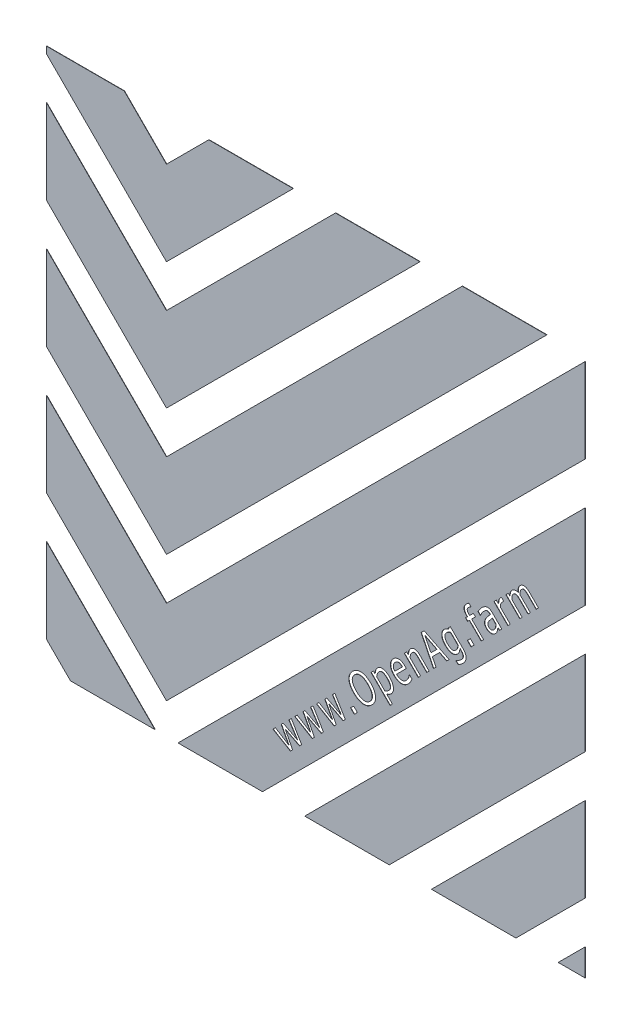
from build123d import *

# Parameters (mm, degrees)
SKETCH1_W           = 228.981
SKETCH1_H           = 228.6
BOSS_EXTRUDE1_DEPTH = 0.127
CUT_EXTRUDE1_DEPTH  = 1.127
CUT_EXTRUDE2_DEPTH  = 1.127


with BuildPart() as part:
    # Sketch1 → Boss-Extrude1 (new body)
    with BuildSketch(Plane.XY):
        Rectangle(SKETCH1_W, SKETCH1_H)
    extrude(amount=BOSS_EXTRUDE1_DEPTH)

    # Sketch2 → Cut-Extrude1 (cut, through all)
    with BuildSketch(Plane.XY.offset(0.127)):
        Polygon((-63.5, 114.3), (834.525612107, 1012.325612107), (834.525612107, 994.365099865), (-63.5, 96.339487758), (-961.525612107, 994.365099865), (-961.525612107, 1012.325612107), align=None)
        Polygon((834.525612107, 958.444075381), (834.525612107, 940.483563138), (-63.5, 42.457951031), (-961.525612107, 940.483563138), (-961.525612107, 958.444075381), (-63.5, 60.418463274), align=None)
        Polygon((834.525612107, 904.562538654), (834.525612107, 886.602026412), (-63.5, -11.423585695), (-961.525612107, 886.602026412), (-961.525612107, 904.562538654), (-63.5, 6.536926547), align=None)
        Polygon((834.525612107, 850.681001928), (834.525612107, 832.720489686), (-63.5, -65.305122421), (-961.525612107, 832.720489686), (-961.525612107, 850.681001928), (-63.5, -47.344610179), align=None)
        Polygon((834.525612107, 796.799465201), (834.525612107, 778.838952959), (-63.5, -119.186659148), (-961.525612107, 778.838952959), (-961.525612107, 796.799465201), (-63.5, -101.226146906), align=None)
        Polygon((834.525612107, 742.917928475), (834.525612107, 724.957416233), (-63.5, -173.068195874), (-961.525612107, 724.957416233), (-961.525612107, 742.917928475), (-63.5, -155.107683632), align=None)
        Polygon((834.525612107, 689.036391748), (834.525612107, 671.075879506), (-63.5, -226.949732601), (-961.525612107, 671.075879506), (-961.525612107, 689.036391748), (-63.5, -208.989220358), align=None)
        Polygon((834.525612107, 635.154855022), (834.525612107, 617.19434278), (-63.5, -280.831269327), (-961.525612107, 617.19434278), (-961.525612107, 635.154855022), (-63.5, -262.870757085), align=None)
        Polygon((834.525612107, 581.273318296), (834.525612107, 563.312806053), (-63.5, -334.712806053), (-961.525612107, 563.312806053), (-961.525612107, 581.273318296), (-63.5, -316.752293811), align=None)
        Polygon((834.525612107, 527.391781569), (834.525612107, 509.431269327), (-63.5, -388.59434278), (-961.525612107, 509.431269327), (-961.525612107, 527.391781569), (-63.5, -370.633830538), align=None)
        Polygon((834.525612107, 473.510244843), (834.525612107, 455.549732601), (-63.5, -442.475879506), (-961.525612107, 455.549732601), (-961.525612107, 473.510244843), (-63.5, -424.515367264), align=None)
        Polygon((834.525612107, 419.628708116), (834.525612107, 401.668195874), (-63.5, -496.357416233), (-961.525612107, 401.668195874), (-961.525612107, 419.628708116), (-63.5, -478.396903991), align=None)
        Polygon((834.525612107, 365.74717139), (834.525612107, 347.786659148), (-63.5, -550.238952959), (-961.525612107, 347.786659148), (-961.525612107, 365.74717139), (-63.5, -532.278440717), align=None)
        Polygon((834.525612107, 311.865634664), (834.525612107, 293.905122421), (-63.5, -604.120489686), (-961.525612107, 293.905122421), (-961.525612107, 311.865634664), (-63.5, -586.159977443), align=None)
        Polygon((834.525612107, 257.984097937), (834.525612107, 240.023585695), (-63.5, -658.002026412), (-961.525612107, 240.023585695), (-961.525612107, 257.984097937), (-63.5, -640.04151417), align=None)
        Polygon((834.525612107, 204.102561211), (834.525612107, 186.142048969), (-63.5, -711.883563138), (-961.525612107, 186.142048969), (-961.525612107, 204.102561211), (-63.5, -693.923050896), align=None)
        Polygon((834.525612107, 150.221024484), (834.525612107, 132.260512242), (-63.5, -765.765099865), (-961.525612107, 132.260512242), (-961.525612107, 150.221024484), (-63.5, -747.804587623), align=None)
        Polygon((834.525612107, 96.339487758), (834.525612107, 78.378975516), (-63.5, -819.646636591), (-961.525612107, 78.378975516), (-961.525612107, 96.339487758), (-63.5, -801.686124349), align=None)
        Polygon((834.525612107, 42.457951031), (834.525612107, 24.497438789), (-63.5, -873.528173318), (-961.525612107, 24.497438789), (-961.525612107, 42.457951031), (-63.5, -855.567661075), align=None)
        Polygon((834.525612107, -11.423585695), (834.525612107, -29.384097937), (-63.5, -927.409710044), (-961.525612107, -29.384097937), (-961.525612107, -11.423585695), (-63.5, -909.449197802), align=None)
    extrude(amount=-CUT_EXTRUDE1_DEPTH, mode=Mode.SUBTRACT)

    # Sketch3 → Cut-Extrude2 (cut, through all)
    with BuildSketch(Plane.XY.offset(0.127)):
        Polygon((-10.447003351, -81.210380229), (-6.029633889, -88.6570614), (-6.961034205, -89.588461716), (-12.994790139, -86.475504833), (-9.870529854, -92.497957365), (-10.79740881, -93.424836321), (-18.259914743, -89.023291621), (-17.213219727, -87.976596605), (-11.561518778, -91.512300719), (-14.737774711, -85.50115159), (-13.910365692, -84.673742571), (-7.860784996, -87.811566938), (-11.491437686, -82.254814564), align=None)
        Polygon((-1.178502119, -71.941878997), (3.238867343, -79.388560168), (2.307467027, -80.319960484), (-3.726288907, -77.207003602), (-0.602028622, -83.229456133), (-1.528907578, -84.156335089), (-8.991413511, -79.75479039), (-7.944718496, -78.708095374), (-2.293017546, -82.243799488), (-5.46927348, -76.232650358), (-4.641864461, -75.405241339), (1.407716235, -78.543065706), (-2.222936454, -72.986313333), align=None)
        Polygon((8.089999113, -62.673377765), (12.507368575, -70.120058936), (11.575968258, -71.051459253), (5.542212325, -67.93850237), (8.666472609, -73.960954902), (7.739593654, -74.887833857), (0.27708772, -70.486289158), (1.323782736, -69.439594142), (6.975483685, -72.975298256), (3.799227752, -66.964149126), (4.626636771, -66.136740107), (10.676217467, -69.274564474), (7.045564777, -63.717812101), align=None)
        Polygon((17.647867433, -64.979560078), (16.345715534, -66.281711977), (14.754196547, -64.69019299), (16.056348446, -63.388041091), align=None)
        with BuildLine():
            add(Edge.make_bspline(
                [(19.304709374, -49.265807535), (19.471059167, -49.280830519), (19.808375555, -49.311293428), (20.313197827, -49.429785868), (20.823195349, -49.599020368), (21.335448339, -49.829332674), (21.846274935, -50.118732028), (22.357241063, -50.461907248), (22.85714262, -50.872605401), (23.176216369, -51.177699523), (23.340023852, -51.334330083)],
                knots=[0, 0, 0, 0, 0.000500551, 0.001014993, 0.001551161, 0.002110774, 0.002696831, 0.003310675, 0.003955033, 0.004634836, 0.004634836, 0.004634836, 0.004634836], degree=3))
            add(Edge.make_bspline(
                [(23.340023852, -51.334330083), (23.493986675, -51.494092257), (23.794513245, -51.805938829), (24.194261422, -52.30213131), (24.538829272, -52.806475395), (24.829342538, -53.317299037), (25.063089531, -53.83016175), (25.239425424, -54.341315835), (25.356725509, -54.850892024), (25.385354159, -55.192007697), (25.399503678, -55.360601839)],
                knots=[0, 0, 0, 0, 0.00066537, 0.001298764, 0.001908867, 0.002496035, 0.003059566, 0.003597181, 0.004116035, 0.004623078, 0.004623078, 0.004623078, 0.004623078], degree=3))
            add(Edge.make_bspline(
                [(25.399503678, -55.360601839), (25.402770364, -55.53330125), (25.409239663, -55.875312778), (25.348404407, -56.382520672), (25.23042187, -56.874063043), (25.054216063, -57.348650398), (24.826457383, -57.80707622), (24.548798257, -58.25011824), (24.220219469, -58.676617242), (23.96941778, -58.940649561), (23.841894897, -59.074899703)],
                knots=[0, 0, 0, 0, 0.000517701, 0.001025247, 0.001527505, 0.002031033, 0.002540585, 0.003060586, 0.00359732, 0.004152532, 0.004152532, 0.004152532, 0.004152532], degree=3))
            add(Edge.make_bspline(
                [(23.841894897, -59.074899703), (23.704079397, -59.206433796), (23.433600775, -59.464584443), (22.996114592, -59.798636709), (22.546185168, -60.079959151), (22.082994171, -60.304472456), (21.608618935, -60.477308058), (21.121592811, -60.586214552), (20.625714602, -60.647071348), (20.292775527, -60.638885786), (20.125336352, -60.634769165)],
                knots=[0, 0, 0, 0, 0.000571183, 0.001121012, 0.001647964, 0.00216058, 0.002662563, 0.003158869, 0.003654927, 0.004156799, 0.004156799, 0.004156799, 0.004156799], degree=3))
            add(Edge.make_bspline(
                [(20.125336352, -60.634769165), (19.958206669, -60.619900736), (19.619177111, -60.589739504), (19.113554875, -60.46904976), (18.603842705, -60.296576564), (18.093588056, -60.064261852), (17.583270372, -59.777108506), (17.082154625, -59.427090651), (16.581085207, -59.027885627), (16.266931422, -58.724216165), (16.105846637, -58.568507298)],
                knots=[0, 0, 0, 0, 0.000502797, 0.001019944, 0.00155469, 0.002115229, 0.002699316, 0.003308833, 0.003947166, 0.004618927, 0.004618927, 0.004618927, 0.004618927], degree=3))
            add(Edge.make_bspline(
                [(16.105846637, -58.568507298), (15.947340766, -58.404247148), (15.639227568, -58.084948439), (15.231490763, -57.581611523), (14.885203363, -57.077269394), (14.603132169, -56.569396571), (14.376694939, -56.062055884), (14.210892435, -55.552230369), (14.086711278, -55.044746511), (14.053681719, -54.702625541), (14.03732409, -54.53319282)],
                knots=[0, 0, 0, 0, 0.000684542, 0.001330654, 0.001940757, 0.002517585, 0.00307123, 0.00360454, 0.004124398, 0.004634456, 0.004634456, 0.004634456, 0.004634456], degree=3))
            add(Edge.make_bspline(
                [(14.03732409, -54.53319282), (14.033035329, -54.367992475), (14.024466579, -54.037929689), (14.088537248, -53.54679125), (14.197958705, -53.061489118), (14.36991338, -52.586931647), (14.593648697, -52.121727444), (14.875548176, -51.673211946), (15.205606051, -51.234612702), (15.463166011, -50.965576002), (15.594932871, -50.827937678)],
                knots=[0, 0, 0, 0, 0.000495089, 0.000989165, 0.001481065, 0.001985176, 0.002499827, 0.003026779, 0.003572067, 0.004143251, 0.004143251, 0.004143251, 0.004143251], degree=3))
            add(Edge.make_bspline(
                [(15.594932871, -50.827937678), (15.734260324, -50.695652165), (16.007009057, -50.436688802), (16.448250423, -50.100638948), (16.903917234, -49.820381825), (17.373730895, -49.598263174), (17.851249167, -49.430481883), (18.333631552, -49.315883397), (18.819444355, -49.256831503), (19.143319626, -49.262822281), (19.304709374, -49.265807535)],
                knots=[0, 0, 0, 0, 0.000576043, 0.001127668, 0.001660393, 0.002178148, 0.002683636, 0.00317605, 0.003663125, 0.004146916, 0.004146916, 0.004146916, 0.004146916], degree=3))
        make_face()
        with BuildLine():
            add(Edge.make_bspline(
                [(22.182555498, -52.491798437), (22.051343106, -52.365178332), (21.79617835, -52.118944056), (21.400663086, -51.785150207), (21.003364608, -51.498720085), (20.608308216, -51.257218992), (20.219897623, -51.056325091), (19.837713082, -50.90167991), (19.464148844, -50.787076342), (19.214114469, -50.746157719), (19.092205419, -50.726207061)],
                knots=[0, 0, 0, 0, 0.000546935, 0.001063608, 0.001551103, 0.002014813, 0.002451587, 0.002861313, 0.003250426, 0.00362066, 0.00362066, 0.00362066, 0.00362066], degree=3))
            add(Edge.make_bspline(
                [(19.092205419, -50.726207061), (18.970994004, -50.71383405), (18.731756672, -50.689413197), (18.374804507, -50.710929231), (18.026522151, -50.768111221), (17.690335764, -50.874102082), (17.363757599, -51.017211684), (17.050426913, -51.202535528), (16.747991865, -51.426928994), (16.562303405, -51.602123988), (16.467555498, -51.691517583)],
                knots=[0, 0, 0, 0, 0.000364979, 0.000720366, 0.001068981, 0.001421509, 0.001774769, 0.002136513, 0.002511336, 0.002901852, 0.002901852, 0.002901852, 0.002901852], degree=3))
            add(Edge.make_bspline(
                [(16.467555498, -51.691517583), (16.374928861, -51.788333921), (16.195126005, -51.976269648), (15.968063997, -52.283162811), (15.781008809, -52.594211251), (15.638094165, -52.915120613), (15.53993042, -53.246632082), (15.484478651, -53.592101942), (15.463802144, -53.952601519), (15.486274173, -54.196449128), (15.497723615, -54.320688864)],
                knots=[0, 0, 0, 0, 0.000401619, 0.000779606, 0.0011425, 0.001488642, 0.001830551, 0.002176561, 0.002536464, 0.002910304, 0.002910304, 0.002910304, 0.002910304], degree=3))
            add(Edge.make_bspline(
                [(15.497723615, -54.320688864), (15.516554627, -54.444180301), (15.555213567, -54.69770083), (15.673579672, -55.07520019), (15.829756914, -55.461316938), (16.031913333, -55.852453453), (16.279750601, -56.244830563), (16.567472543, -56.638336507), (16.896333735, -57.030791321), (17.138900638, -57.282127013), (17.263314991, -57.411038944)],
                knots=[0, 0, 0, 0, 0.000374277, 0.000768369, 0.001183135, 0.001622952, 0.002087119, 0.00257411, 0.003084414, 0.003621762, 0.003621762, 0.003621762, 0.003621762], degree=3))
            add(Edge.make_bspline(
                [(17.263314991, -57.411038944), (17.392824181, -57.537136785), (17.644246934, -57.781936916), (18.037368666, -58.109836909), (18.425517467, -58.396842946), (18.813555575, -58.637699222), (19.198818629, -58.835945567), (19.58189776, -58.991554391), (19.963721952, -59.101765884), (20.342412424, -59.164411593), (20.713705327, -59.187949259), (21.074831647, -59.170419368), (21.423996897, -59.111345384), (21.760986033, -59.011066855), (22.086542172, -58.869733896), (22.398784164, -58.687154981), (22.701490599, -58.467019204), (22.884551064, -58.291948588), (22.978314991, -58.202277076)],
                knots=[0, 0, 0, 0, 0.000542097, 0.0010524, 0.001534408, 0.001989232, 0.002420951, 0.002832773, 0.003227765, 0.003610568, 0.003982009, 0.004341911, 0.004692754, 0.005041808, 0.005394162, 0.005754767, 0.006125085, 0.006513928, 0.006513928, 0.006513928, 0.006513928], degree=3))
            add(Edge.make_bspline(
                [(22.978314991, -58.202277076), (23.06798111, -58.108511571), (23.243041196, -57.925448024), (23.463252409, -57.622763664), (23.645556906, -57.310441369), (23.787798917, -56.985371492), (23.884391841, -56.647528307), (23.944314374, -56.299590842), (23.961501353, -55.939192338), (23.938926239, -55.568389338), (23.872568307, -55.19017534), (23.763234523, -54.809155053), (23.609550244, -54.426332855), (23.411725067, -54.041393852), (23.167985447, -53.654708706), (22.881530813, -53.265739727), (22.553404778, -52.872761236), (22.308636785, -52.621318117), (22.182555498, -52.491798437)],
                knots=[0, 0, 0, 0, 0.000388844, 0.000759161, 0.001119766, 0.00147212, 0.001820536, 0.002171379, 0.002529024, 0.002900464, 0.003283648, 0.00367864, 0.004087523, 0.004519242, 0.004975261, 0.005457269, 0.005967572, 0.006509669, 0.006509669, 0.006509669, 0.006509669], degree=3))
        make_face(mode=Mode.SUBTRACT)
        with BuildLine():
            add(Edge.make_bspline(
                [(31.340239678, -45.088402231), (31.458904103, -45.211060495), (31.690054366, -45.449990485), (31.998017847, -45.828505087), (32.269134541, -46.207325943), (32.496725095, -46.592877708), (32.680304401, -46.983047772), (32.824491834, -47.376216784), (32.926659252, -47.773061077), (32.987731094, -48.17067299), (33.008722859, -48.562311358), (32.988480399, -48.941966804), (32.929873119, -49.305934133), (32.832668683, -49.65459953), (32.693859733, -49.987332079), (32.51231026, -50.302758647), (32.296566901, -50.605961812), (32.123983106, -50.7880137), (32.036529235, -50.880265364)],
                knots=[0, 0, 0, 0, 0.000511783, 0.000996919, 0.001462339, 0.001908215, 0.002338012, 0.002754235, 0.003162725, 0.003565259, 0.003959143, 0.004337225, 0.004703678, 0.005062963, 0.005420672, 0.005782113, 0.006152926, 0.006533863, 0.006533863, 0.006533863, 0.006533863], degree=3))
            add(Edge.make_bspline(
                [(32.036529235, -50.880265364), (31.962695593, -50.951179976), (31.818638158, -51.089542064), (31.595542376, -51.277612976), (31.370878979, -51.439119124), (31.143627219, -51.576475666), (30.909008084, -51.696739166), (30.66009252, -51.798778795), (30.396479173, -51.893291036), (30.213282182, -51.943964754), (30.119472273, -51.969913307)],
                knots=[0, 0, 0, 0, 0.00030707, 0.000599127, 0.00087454, 0.001136243, 0.001395069, 0.001664611, 0.001942749, 0.002234648, 0.002234648, 0.002234648, 0.002234648], degree=3))
            Line((30.119472273, -51.969913307), (32.558746403, -54.409187437))
            Line((32.558746403, -54.409187437), (31.545961593, -55.421972247))
            Line((31.545961593, -55.421972247), (23.443683112, -47.319693766))
            Line((23.443683112, -47.319693766), (24.456467922, -46.306908956))
            Line((24.456467922, -46.306908956), (25.09850115, -46.948942184))
            add(Edge.make_bspline(
                [(25.09850115, -46.948942184), (25.108026931, -46.830423789), (25.12710488, -46.593058685), (25.187835668, -46.240629264), (25.269067448, -45.890796203), (25.374140675, -45.545024744), (25.509188894, -45.207456815), (25.689222582, -44.888788871), (25.902566574, -44.58531134), (26.074237817, -44.404428574), (26.161020928, -44.312988861)],
                knots=[0, 0, 0, 0, 0.000356543, 0.000714074, 0.001071605, 0.001433441, 0.001797417, 0.002159719, 0.002529214, 0.002906957, 0.002906957, 0.002906957, 0.002906957], degree=3))
            add(Edge.make_bspline(
                [(26.161020928, -44.312988861), (26.247395669, -44.231013932), (26.416832842, -44.070207658), (26.69627587, -43.869444164), (26.985797333, -43.706626105), (27.285481688, -43.583458503), (27.596978945, -43.500576202), (27.919364232, -43.461007025), (28.252335313, -43.459141629), (28.594269457, -43.495817606), (28.940460108, -43.571724446), (29.289036897, -43.679180923), (29.632852434, -43.830528993), (29.980759565, -44.00711016), (30.323488372, -44.226686306), (30.666219354, -44.478953377), (31.008565969, -44.766465794), (31.227760032, -44.97922476), (31.340239678, -45.088402231)],
                knots=[0, 0, 0, 0, 0.000356908, 0.00070013, 0.001029057, 0.001351472, 0.001669513, 0.001993099, 0.002323166, 0.002666439, 0.003022488, 0.003384994, 0.003758718, 0.004147989, 0.004554408, 0.004978079, 0.005424127, 0.005894273, 0.005894273, 0.005894273, 0.005894273], degree=3))
        make_face()
        with BuildLine():
            add(Edge.make_bspline(
                [(30.411100042, -46.184832216), (30.326212056, -46.100839504), (30.161173597, -45.937541631), (29.90382909, -45.717752077), (29.655781398, -45.51636169), (29.409894141, -45.342193684), (29.167232431, -45.194403673), (28.92839703, -45.071502445), (28.694800376, -44.971159968), (28.464792945, -44.898000943), (28.239185494, -44.850133311), (28.017012257, -44.837637107), (27.799524805, -44.851278439), (27.588509545, -44.903983822), (27.38193258, -44.983551703), (27.178541534, -45.092540976), (26.983616323, -45.237182273), (26.862954779, -45.350856964), (26.800793476, -45.409418845)],
                knots=[0, 0, 0, 0, 0.000358131, 0.000696274, 0.001014733, 0.001316431, 0.001599458, 0.001866381, 0.002121668, 0.002361183, 0.002589512, 0.002811473, 0.00302682, 0.003240667, 0.00346108, 0.003689677, 0.003930681, 0.004186767, 0.004186767, 0.004186767, 0.004186767], degree=3))
            add(Edge.make_bspline(
                [(26.800793476, -45.409418845), (26.730130185, -45.483795044), (26.588950956, -45.632392346), (26.414595837, -45.886592609), (26.262677251, -46.157488582), (26.142545846, -46.44912328), (26.047130758, -46.754948121), (25.967254018, -47.069420825), (25.907667014, -47.393421339), (25.885232537, -47.613385409), (25.87391452, -47.724355554)],
                knots=[0, 0, 0, 0, 0.000307336, 0.000614031, 0.000921658, 0.001237806, 0.001558106, 0.001882149, 0.002210726, 0.002545261, 0.002545261, 0.002545261, 0.002545261], degree=3))
            Line((25.87391452, -47.724355554), (29.32597346, -51.176414494))
            add(Edge.make_bspline(
                [(29.32597346, -51.176414494), (29.42125614, -51.142637869), (29.60347512, -51.078043315), (29.858309968, -50.971960662), (30.083194364, -50.86570559), (30.284428282, -50.757366886), (30.470447706, -50.635490306), (30.653540356, -50.497701219), (30.836501539, -50.338457033), (30.955705227, -50.22297456), (31.016962384, -50.163629684)],
                knots=[0, 0, 0, 0, 0.000303235, 0.000579907, 0.000827656, 0.001049214, 0.001264916, 0.00149415, 0.001736169, 0.001992016, 0.001992016, 0.001992016, 0.001992016], degree=3))
            add(Edge.make_bspline(
                [(31.016962384, -50.163629684), (31.080196536, -50.097064404), (31.203573453, -49.967188083), (31.360884323, -49.754984002), (31.48763398, -49.53546263), (31.5868022, -49.309105498), (31.65530784, -49.075945651), (31.690652291, -48.834844315), (31.70019811, -48.587614742), (31.679022948, -48.333553908), (31.628972412, -48.074155607), (31.546881422, -47.81117209), (31.43166034, -47.545843934), (31.289502058, -47.277089231), (31.115625613, -47.005652769), (30.909069801, -46.733650286), (30.673263669, -46.45689239), (30.500261263, -46.277359229), (30.411100042, -46.184832216)],
                knots=[0, 0, 0, 0, 0.000275247, 0.000537037, 0.000790243, 0.00103425, 0.001276776, 0.001516887, 0.001763467, 0.00201748, 0.002279952, 0.00255453, 0.00284217, 0.003146565, 0.00346577, 0.003808037, 0.004170452, 0.004555863, 0.004555863, 0.004555863, 0.004555863], degree=3))
        make_face(mode=Mode.SUBTRACT)
        with BuildLine():
            add(Edge.make_bspline(
                [(39.324455892, -43.592338708), (39.205711602, -43.706664063), (38.975257816, -43.928541773), (38.607656376, -44.219559657), (38.237200835, -44.467611995), (37.86039653, -44.670383787), (37.478154873, -44.828460482), (37.090559023, -44.939517673), (36.697795533, -45.006285708), (36.301800676, -45.026261319), (35.905041531, -45.001645096), (35.510932812, -44.930164424), (35.120332366, -44.815575994), (34.736318889, -44.64804668), (34.35259027, -44.443970328), (33.977045163, -44.186295906), (33.602215865, -43.888603504), (33.366490303, -43.661461971), (33.245486351, -43.54486442)],
                knots=[0, 0, 0, 0, 0.000494262, 0.000959243, 0.001404414, 0.00183022, 0.0022408, 0.002642934, 0.00303726, 0.003433401, 0.003829801, 0.004227128, 0.004632698, 0.005047981, 0.005481902, 0.005934603, 0.006412292, 0.00691614, 0.00691614, 0.00691614, 0.00691614], degree=3))
            add(Edge.make_bspline(
                [(33.245486351, -43.54486442), (33.129526912, -43.425476296), (32.903299088, -43.192559375), (32.607939721, -42.818630057), (32.349503949, -42.443405813), (32.136140767, -42.060304745), (31.965453359, -41.671149219), (31.834480957, -41.277326238), (31.751531686, -40.875877851), (31.707756128, -40.473001117), (31.708304824, -40.072934692), (31.747814742, -39.681546673), (31.832728206, -39.301918044), (31.957345109, -38.934153927), (32.123717731, -38.578244516), (32.334257879, -38.236536645), (32.582359894, -37.903353638), (32.777464283, -37.70049916), (32.876995449, -37.597014341)],
                knots=[0, 0, 0, 0, 0.000499001, 0.000973513, 0.001427482, 0.001864659, 0.002286783, 0.00270071, 0.003107287, 0.003514222, 0.003914363, 0.004305323, 0.004692012, 0.005078773, 0.005468142, 0.005867874, 0.006281127, 0.006711494, 0.006711494, 0.006711494, 0.006711494], degree=3))
            add(Edge.make_bspline(
                [(32.876995449, -37.597014341), (32.969563661, -37.507003193), (33.149526699, -37.332011376), (33.43952413, -37.10681121), (33.727735196, -36.911920569), (34.023020466, -36.757035426), (34.323656502, -36.634129702), (34.633865398, -36.552733339), (34.951884023, -36.498496195), (35.166835169, -36.496880409), (35.275577332, -36.496062996)],
                knots=[0, 0, 0, 0, 0.000387059, 0.000752486, 0.001099844, 0.001429508, 0.001751074, 0.002071883, 0.002390029, 0.002715764, 0.002715764, 0.002715764, 0.002715764], degree=3))
            add(Edge.make_bspline(
                [(35.275577332, -36.496062996), (35.385090075, -36.501955643), (35.606419241, -36.513864895), (35.937285865, -36.576421837), (36.266859659, -36.677753831), (36.598019792, -36.814085011), (36.931579209, -36.995555805), (37.268500401, -37.225781602), (37.610484388, -37.505576569), (37.830876145, -37.717461215), (37.94544086, -37.827603739)],
                knots=[0, 0, 0, 0, 0.000328741, 0.000664396, 0.001006955, 0.001361709, 0.001736988, 0.002143924, 0.002584205, 0.003060839, 0.003060839, 0.003060839, 0.003060839], degree=3))
            Line((37.94544086, -37.827603739), (38.47896143, -38.361124309))
            Line((38.47896143, -38.361124309), (34.283138645, -42.556947094))
            add(Edge.make_bspline(
                [(34.283138645, -42.556947094), (34.370021655, -42.641267712), (34.538443485, -42.804722372), (34.805755928, -43.020080877), (35.071036157, -43.206843608), (35.339338154, -43.359141041), (35.607651907, -43.480542454), (35.877167919, -43.570137976), (36.14914271, -43.623902697), (36.420420878, -43.649705829), (36.690617357, -43.64296278), (36.956067086, -43.604185481), (37.216497003, -43.534889986), (37.472887397, -43.438466574), (37.72285785, -43.306537471), (37.969353974, -43.148649005), (38.210477095, -42.959732172), (38.361083211, -42.815990708), (38.438269183, -42.742322885)],
                knots=[0, 0, 0, 0, 0.000363042, 0.000703752, 0.001028599, 0.001335361, 0.001627794, 0.001910894, 0.002185331, 0.00245775, 0.002726857, 0.002994134, 0.003260626, 0.003533953, 0.003814031, 0.004106883, 0.004411237, 0.004731201, 0.004731201, 0.004731201, 0.004731201], degree=3))
            add(Edge.make_bspline(
                [(38.438269183, -42.742322885), (38.545239171, -42.627969218), (38.75760785, -42.40094164), (39.020032049, -42.021742681), (39.240316937, -41.637080343), (39.349001177, -41.369862861), (39.401319025, -41.241231113)],
                knots=[0, 0, 0, 0, 0.000469161, 0.00093143, 0.001379809, 0.001795983, 0.001795983, 0.001795983, 0.001795983], degree=3))
            add(Edge.make_bspline(
                [(39.401319025, -41.241231113), (39.44671045, -41.117451258), (39.530959828, -40.887707957), (39.624326436, -40.558716521), (39.687479036, -40.272335938), (39.711338724, -40.093737082), (39.722335639, -40.011420986)],
                knots=[0, 0, 0, 0, 0.000395386, 0.000733862, 0.001025175, 0.001274229, 0.001274229, 0.001274229, 0.001274229], degree=3))
            Line((39.722335639, -40.011420986), (39.781113329, -39.952643296))
            Line((39.781113329, -39.952643296), (40.866239911, -41.037769879))
            add(Edge.make_bspline(
                [(40.866239911, -41.037769879), (40.847522283, -41.081528698), (40.808101873, -41.173687307), (40.743003279, -41.31878283), (40.677551062, -41.481704478), (40.576515164, -41.708933606), (40.457200755, -41.98380716), (40.346033047, -42.191330273), (40.294287775, -42.287926129)],
                knots=[0, 0, 0, 0, 0.000142781, 0.000300706, 0.000477039, 0.000669396, 0.001046767, 0.001375383, 0.001375383, 0.001375383, 0.001375383], degree=3))
            add(Edge.make_bspline(
                [(40.294287775, -42.287926129), (40.224993056, -42.405934938), (40.093685208, -42.629552018), (39.92141399, -42.899130462), (39.771166958, -43.099365113), (39.641530796, -43.25491548), (39.492911709, -43.422937602), (39.382334601, -43.534135213), (39.324455892, -43.592338708)],
                knots=[0, 0, 0, 0, 0.00041058, 0.000778015, 0.000958869, 0.001161197, 0.001385358, 0.001631554, 0.001631554, 0.001631554, 0.001631554], degree=3))
        make_face()
        with BuildLine():
            add(Edge.make_bspline(
                [(36.742758898, -38.650491398), (36.677070905, -38.590258768), (36.550138289, -38.473867859), (36.355888176, -38.316460127), (36.163501191, -38.18600101), (35.976642896, -38.075613608), (35.793066458, -37.986471222), (35.610460778, -37.918736884), (35.430238446, -37.866240281), (35.308280925, -37.850936474), (35.248449167, -37.843428502)],
                knots=[0, 0, 0, 0, 0.000267344, 0.000516604, 0.000749234, 0.000964035, 0.00116727, 0.001360422, 0.001547991, 0.001728633, 0.001728633, 0.001728633, 0.001728633], degree=3))
            add(Edge.make_bspline(
                [(35.248449167, -37.843428502), (35.182893798, -37.84043709), (35.051523879, -37.834442439), (34.853561237, -37.852348426), (34.656699131, -37.899653742), (34.459090512, -37.969707136), (34.26087303, -38.068057282), (34.061646429, -38.198006983), (33.85934169, -38.357426515), (33.730453652, -38.481995291), (33.663712221, -38.5465001)],
                knots=[0, 0, 0, 0, 0.000196731, 0.00039424, 0.000593847, 0.000802639, 0.00102203, 0.001255931, 0.001515082, 0.001793394, 0.001793394, 0.001793394, 0.001793394], degree=3))
            add(Edge.make_bspline(
                [(33.663712221, -38.5465001), (33.601035098, -38.612746714), (33.480119953, -38.740548031), (33.319078928, -38.939194489), (33.193154001, -39.141790057), (33.09055373, -39.343194576), (33.016563571, -39.548772493), (32.961170536, -39.758960943), (32.927382326, -39.976491014), (32.919440186, -40.124346124), (32.915427015, -40.199057458)],
                knots=[0, 0, 0, 0, 0.00027358, 0.000527783, 0.000765499, 0.00098792, 0.001204628, 0.001419571, 0.001639229, 0.001863595, 0.001863595, 0.001863595, 0.001863595], degree=3))
            add(Edge.make_bspline(
                [(32.915427015, -40.199057458), (32.916967508, -40.273003111), (32.920013998, -40.419238622), (32.950269966, -40.635101382), (33.000436298, -40.843734154), (33.068677016, -41.046723325), (33.157430034, -41.246647901), (33.273575283, -41.441769592), (33.402167549, -41.643269357), (33.506297668, -41.769015937), (33.559720924, -41.833529372)],
                knots=[0, 0, 0, 0, 0.000221731, 0.000438497, 0.000652344, 0.000864667, 0.001080204, 0.001307051, 0.001545314, 0.001796341, 0.001796341, 0.001796341, 0.001796341], degree=3))
            Line((33.559720924, -41.833529372), (36.742758898, -38.650491398))
        make_face(mode=Mode.SUBTRACT)
        with BuildLine():
            Line((48.143395551, -34.48403196), (47.130610741, -35.49681677))
            Line((47.130610741, -35.49681677), (43.712462007, -32.078668036))
            add(Edge.make_bspline(
                [(43.712462007, -32.078668036), (43.577670109, -31.946573832), (43.317216452, -31.691332838), (42.976779448, -31.402890917), (42.714807214, -31.201848868), (42.530626112, -31.080196425), (42.354764389, -30.985227181), (42.23602833, -30.94179589), (42.17972071, -30.921199681)],
                knots=[0, 0, 0, 0, 0.000566029, 0.001093717, 0.00133742, 0.001556251, 0.001755461, 0.001935138, 0.001935138, 0.001935138, 0.001935138], degree=3))
            add(Edge.make_bspline(
                [(42.17972071, -30.921199681), (42.123550032, -30.906037397), (42.012522318, -30.876067423), (41.84214256, -30.859431032), (41.674409419, -30.874523898), (41.507853723, -30.913273509), (41.339723717, -30.983012965), (41.169311276, -31.087875083), (40.993065399, -31.223893992), (40.880305345, -31.33223114), (40.821051801, -31.38916052)],
                knots=[0, 0, 0, 0, 0.000174366, 0.000344654, 0.00051024, 0.000677484, 0.000855906, 0.001053635, 0.001276103, 0.001522465, 0.001522465, 0.001522465, 0.001522465], degree=3))
            add(Edge.make_bspline(
                [(40.821051801, -31.38916052), (40.762534675, -31.452383677), (40.643284128, -31.581224522), (40.498519051, -31.809215981), (40.370058767, -32.061369913), (40.268830335, -32.341682747), (40.186526283, -32.640705347), (40.121305653, -32.954971899), (40.070589253, -33.281622839), (40.052529092, -33.50500198), (40.043377751, -33.618191374)],
                knots=[0, 0, 0, 0, 0.000257965, 0.000525701, 0.000806763, 0.001105754, 0.001417843, 0.001736631, 0.002068181, 0.002408757, 0.002408757, 0.002408757, 0.002408757], degree=3))
            Line((40.043377751, -33.618191374), (44.526306944, -38.101120567))
            Line((44.526306944, -38.101120567), (43.513522134, -39.113905377))
            Line((43.513522134, -39.113905377), (37.581496817, -33.181880061))
            Line((37.581496817, -33.181880061), (38.594281627, -32.169095251))
            Line((38.594281627, -32.169095251), (39.270225061, -32.845038684))
            add(Edge.make_bspline(
                [(39.270225061, -32.845038684), (39.278991253, -32.709235339), (39.296045473, -32.44503622), (39.350517845, -32.061964765), (39.427821499, -31.704207235), (39.522849251, -31.368183343), (39.651029934, -31.055101399), (39.809176721, -30.762684035), (39.999760834, -30.490205948), (40.150630205, -30.328718662), (40.226492861, -30.247516928)],
                knots=[0, 0, 0, 0, 0.000408151, 0.00079404, 0.001159404, 0.00150565, 0.001840238, 0.002172035, 0.002501327, 0.002834376, 0.002834376, 0.002834376, 0.002834376], degree=3))
            add(Edge.make_bspline(
                [(40.226492861, -30.247516928), (40.298293148, -30.178958307), (40.43859892, -30.04498711), (40.666042684, -29.873633202), (40.898081625, -29.728415226), (41.137206295, -29.615663612), (41.382912484, -29.53246837), (41.634255698, -29.480832693), (41.89217998, -29.457898224), (42.155201787, -29.465589495), (42.42272359, -29.500411751), (42.690295627, -29.572934746), (42.959230798, -29.673028328), (43.228596866, -29.805015284), (43.498658751, -29.969499192), (43.769009135, -30.164773968), (44.042711906, -30.38867017), (44.215624577, -30.558071213), (44.304760267, -30.645396675)],
                knots=[0, 0, 0, 0, 0.000297604, 0.000581551, 0.000852578, 0.001117531, 0.001372748, 0.001629014, 0.001885469, 0.002147796, 0.002416997, 0.00269281, 0.002977512, 0.003276785, 0.003591215, 0.00392497, 0.004276656, 0.004650838, 0.004650838, 0.004650838, 0.004650838], degree=3))
            Line((44.304760267, -30.645396675), (48.143395551, -34.48403196))
        make_face()
        Polygon((50.012471338, -32.614956173), (44.731521971, -21.980715667), (46.033673869, -20.678563768), (56.667914376, -25.959513135), (55.598612556, -27.028814955), (52.533129961, -25.464424132), (49.517382335, -28.480171759), (51.081773157, -31.545654354), align=None)
        Polygon((51.384704328, -24.876647233), (46.399904091, -22.351467249), (48.927344755, -27.334006806), align=None, mode=Mode.SUBTRACT)
        with BuildLine():
            add(Edge.make_bspline(
                [(59.536830701, -24.826799342), (59.564019394, -24.816400342), (59.624020169, -24.793451534), (59.721656299, -24.751909675), (59.835355847, -24.702732435), (60.015141238, -24.624819975), (60.260797215, -24.505096493), (60.458927208, -24.395932487), (60.563179593, -24.33849238)],
                knots=[0, 0, 0, 0, 8.7322e-05, 0.000192705, 0.000318269, 0.000458977, 0.000780503, 0.001137561, 0.001137561, 0.001137561, 0.001137561], degree=3))
            add(Edge.make_bspline(
                [(60.563179593, -24.33849238), (60.675762907, -24.271175938), (60.890782219, -24.142610393), (61.203358674, -23.944644721), (61.49609106, -23.724188362), (61.674116044, -23.553720623), (61.765861555, -23.465869754)],
                knots=[0, 0, 0, 0, 0.000393521, 0.000751573, 0.001109675, 0.001490464, 0.001490464, 0.001490464, 0.001490464], degree=3))
            add(Edge.make_bspline(
                [(61.765861555, -23.465869754), (61.840381197, -23.389532641), (61.984242986, -23.242162186), (62.16895032, -23.008742912), (62.322654871, -22.779337815), (62.443481428, -22.552962672), (62.532605377, -22.329886099), (62.592325743, -22.113211922), (62.621976587, -21.901488832), (62.616374993, -21.763636989), (62.613616697, -21.695757016)],
                knots=[0, 0, 0, 0, 0.000319852, 0.000617482, 0.000891482, 0.001147338, 0.001385784, 0.001610628, 0.001820372, 0.002023846, 0.002023846, 0.002023846, 0.002023846], degree=3))
            add(Edge.make_bspline(
                [(62.613616697, -21.695757016), (62.603709054, -21.630671392), (62.583886619, -21.500453188), (62.528709669, -21.309114083), (62.450896252, -21.123251155), (62.352807446, -20.941011193), (62.232914787, -20.762241118), (62.097848244, -20.580587379), (61.94064947, -20.40002379), (61.826699341, -20.282306868), (61.768122235, -20.221793409)],
                knots=[0, 0, 0, 0, 0.000197354, 0.00039485, 0.000595529, 0.000800853, 0.001014664, 0.001240732, 0.001479563, 0.001732213, 0.001732213, 0.001732213, 0.001732213], degree=3))
            Line((61.768122235, -20.221793409), (61.248165748, -19.701836921))
            add(Edge.make_bspline(
                [(61.248165748, -19.701836921), (61.237221955, -19.825646605), (61.215965902, -20.066121289), (61.154323758, -20.412154187), (61.07247879, -20.733162179), (60.971852287, -21.035983717), (60.831219438, -21.326618314), (60.647952544, -21.614952868), (60.418229494, -21.907087163), (60.240068692, -22.093625504), (60.147214403, -22.190846019)],
                knots=[0, 0, 0, 0, 0.000372738, 0.000723967, 0.001052948, 0.001366083, 0.001679536, 0.002018856, 0.002389236, 0.002792385, 0.002792385, 0.002792385, 0.002792385], degree=3))
            add(Edge.make_bspline(
                [(60.147214403, -22.190846019), (60.061450857, -22.272628154), (59.893381712, -22.432895004), (59.617539616, -22.636853789), (59.331955268, -22.805403536), (59.036218418, -22.937401503), (58.7308796, -23.034496106), (58.413823462, -23.089366683), (58.087222352, -23.113248676), (57.751941884, -23.096435268), (57.411569457, -23.041845427), (57.068827762, -22.947432985), (56.723444114, -22.817467638), (56.381794656, -22.638215004), (56.034208003, -22.429497937), (55.689060459, -22.17521187), (55.338959674, -21.88673878), (55.116407807, -21.669581811), (55.001905859, -21.557855513)],
                knots=[0, 0, 0, 0, 0.000355236, 0.00069615, 0.001026487, 0.001348299, 0.001665762, 0.001985038, 0.00231136, 0.002646315, 0.00298973, 0.003343453, 0.003711242, 0.004094426, 0.004499195, 0.004926518, 0.005379219, 0.005858952, 0.005858952, 0.005858952, 0.005858952], degree=3))
            add(Edge.make_bspline(
                [(55.001905859, -21.557855513), (54.885994952, -21.436909599), (54.660503085, -21.201622681), (54.365563141, -20.825696678), (54.115059035, -20.446154134), (53.912470562, -20.060408396), (53.757255281, -19.672175826), (53.638422227, -19.287665511), (53.558879312, -18.905213338), (53.538182561, -18.650198387), (53.527942251, -18.524022443)],
                knots=[0, 0, 0, 0, 0.000502309, 0.000977186, 0.00143115, 0.001864947, 0.002281808, 0.002683701, 0.003071195, 0.00345068, 0.00345068, 0.00345068, 0.00345068], degree=3))
            add(Edge.make_bspline(
                [(53.527942251, -18.524022443), (53.524450288, -18.404896951), (53.517514531, -18.168289221), (53.555613159, -17.815527358), (53.63094183, -17.4703238), (53.741383769, -17.132736485), (53.888308104, -16.810337866), (54.062230774, -16.504355045), (54.269088504, -16.222398931), (54.427475686, -16.052367219), (54.506816856, -15.967192934)],
                knots=[0, 0, 0, 0, 0.000357195, 0.000709462, 0.001061091, 0.001415679, 0.001772845, 0.002122228, 0.002469939, 0.002818949, 0.002818949, 0.002818949, 0.002818949], degree=3))
            add(Edge.make_bspline(
                [(54.506816856, -15.967192934), (54.584434348, -15.893285562), (54.734516988, -15.75037688), (54.96468704, -15.556107115), (55.195983916, -15.394930024), (55.505250078, -15.218243377), (55.915421501, -15.040122496), (56.259098887, -14.940095721), (56.43517722, -14.888848393)],
                knots=[0, 0, 0, 0, 0.000321502, 0.000621662, 0.000902615, 0.001165913, 0.001689265, 0.002239094, 0.002239094, 0.002239094, 0.002239094], degree=3))
            Line((56.43517722, -14.888848393), (56.213630542, -14.549746336))
            Line((56.213630542, -14.549746336), (57.167637663, -13.595739216))
            Line((57.167637663, -13.595739216), (62.376245257, -18.80434681))
            add(Edge.make_bspline(
                [(62.376245257, -18.80434681), (62.494812116, -18.926323809), (62.724584092, -19.162704332), (63.02943128, -19.532327528), (63.291763668, -19.895695928), (63.50640205, -20.257148396), (63.675175532, -20.615084557), (63.798742657, -20.969562376), (63.878110423, -21.319915597), (63.906771072, -21.668162352), (63.89406599, -22.013855597), (63.833924688, -22.359553248), (63.727455783, -22.703519015), (63.583015559, -23.050629183), (63.387297127, -23.393308361), (63.153556733, -23.738942709), (62.874326635, -24.083764408), (62.662130682, -24.302451776), (62.552578327, -24.415355513)],
                knots=[0, 0, 0, 0, 0.000510138, 0.000988602, 0.001435885, 0.001853451, 0.002247873, 0.00262107, 0.002977599, 0.003322477, 0.003666368, 0.004012754, 0.004371768, 0.004744609, 0.005138312, 0.005553398, 0.005995434, 0.006467224, 0.006467224, 0.006467224, 0.006467224], degree=3))
            add(Edge.make_bspline(
                [(62.552578327, -24.415355513), (62.399450243, -24.56093455), (62.088878599, -24.856195351), (61.58429196, -25.25442134), (61.066428539, -25.620268558), (60.705004289, -25.827156028), (60.529269387, -25.927750687)],
                knots=[0, 0, 0, 0, 0.000633539, 0.001284933, 0.001926477, 0.002533628, 0.002533628, 0.002533628, 0.002533628], degree=3))
            Line((60.529269387, -25.927750687), (59.482574371, -24.881055671))
            Line((59.482574371, -24.881055671), (59.536830701, -24.826799342))
        make_face()
        with BuildLine():
            Line((60.416235368, -18.869906541), (57.255804197, -15.709475371))
            add(Edge.make_bspline(
                [(57.255804197, -15.709475371), (57.161421786, -15.74054447), (56.978241761, -15.800844246), (56.71456356, -15.898209707), (56.475868605, -16.010202185), (56.188062148, -16.161974366), (55.858896493, -16.376049317), (55.632152941, -16.586264002), (55.519601666, -16.690610655)],
                knots=[0, 0, 0, 0, 0.00029811, 0.00057858, 0.000842577, 0.001088326, 0.001554816, 0.002014602, 0.002014602, 0.002014602, 0.002014602], degree=3))
            add(Edge.make_bspline(
                [(55.519601666, -16.690610655), (55.45796085, -16.755748237), (55.337440922, -16.88310503), (55.18269068, -17.090738928), (55.055657585, -17.305034544), (54.956735163, -17.527302519), (54.886786635, -17.756623347), (54.842724094, -17.993225901), (54.83037474, -18.236941957), (54.843563899, -18.486434043), (54.886939827, -18.739729996), (54.960372087, -18.994925761), (55.063244212, -19.250136211), (55.192652144, -19.508157611), (55.355321418, -19.76471564), (55.542587506, -20.026241778), (55.762761603, -20.285390431), (55.924793665, -20.45254572), (56.007908628, -20.538288662)],
                knots=[0, 0, 0, 0, 0.000268859, 0.000525673, 0.000774974, 0.001014841, 0.001253682, 0.001492684, 0.001734957, 0.001984002, 0.002240815, 0.002504143, 0.002779111, 0.003065228, 0.003368842, 0.00368946, 0.00402957, 0.004387772, 0.004387772, 0.004387772, 0.004387772], degree=3))
            add(Edge.make_bspline(
                [(56.007908628, -20.538288662), (56.089335024, -20.617412181), (56.247384111, -20.770991373), (56.488798889, -20.981843198), (56.727787618, -21.165062182), (56.959641623, -21.327674516), (57.189923391, -21.460868298), (57.416257876, -21.568217977), (57.637056382, -21.653411904), (57.856093429, -21.710491063), (58.071630525, -21.742135543), (58.284694167, -21.738336125), (58.494709569, -21.709550195), (58.701532403, -21.649855346), (58.905534462, -21.560580806), (59.103750394, -21.438273431), (59.302413671, -21.291990604), (59.424307847, -21.175015977), (59.487095732, -21.114762159)],
                knots=[0, 0, 0, 0, 0.000340583, 0.000661074, 0.000960868, 0.001243679, 0.001510065, 0.001757814, 0.001994625, 0.002218888, 0.002435654, 0.00264591, 0.002855959, 0.003069913, 0.003289583, 0.003521818, 0.003767328, 0.00402813, 0.00402813, 0.00402813, 0.00402813], degree=3))
            add(Edge.make_bspline(
                [(59.487095732, -21.114762159), (59.551790753, -21.045122966), (59.683307496, -20.903555351), (59.856832142, -20.665946601), (60.008677499, -20.401861515), (60.143509557, -20.118237519), (60.252770037, -19.817416611), (60.337137546, -19.507548319), (60.395408451, -19.191403558), (60.409288325, -18.977145337), (60.416235368, -18.869906541)],
                knots=[0, 0, 0, 0, 0.000284989, 0.000579347, 0.00088023, 0.001197765, 0.001520314, 0.001838942, 0.002160444, 0.002482604, 0.002482604, 0.002482604, 0.002482604], degree=3))
        make_face(mode=Mode.SUBTRACT)
        Polygon((67.283675474, -15.343752037), (65.981523575, -16.645903936), (64.390004588, -15.054384948), (65.692156487, -13.752233049), align=None)
        with BuildLine():
            Line((65.956419314, -1.913286678), (65.904423666, -1.965282326))
            add(Edge.make_bspline(
                [(65.904423666, -1.965282326), (65.871771058, -1.980633256), (65.800610107, -2.014088067), (65.690535554, -2.079551258), (65.563455614, -2.155251969), (65.383828045, -2.276029606), (65.165857867, -2.428344987), (65.013063664, -2.571702745), (64.941373824, -2.638965079)],
                knots=[0, 0, 0, 0, 0.000108182, 0.000235766, 0.000383871, 0.000551908, 0.000885157, 0.001179723, 0.001179723, 0.001179723, 0.001179723], degree=3))
            add(Edge.make_bspline(
                [(64.941373824, -2.638965079), (64.891460961, -2.690133342), (64.795497889, -2.78851006), (64.671409849, -2.94435842), (64.563476616, -3.094366276), (64.479457633, -3.244864579), (64.414533257, -3.392959222), (64.371602188, -3.539674889), (64.348030668, -3.684723439), (64.345116302, -3.829581887), (64.367068417, -3.977146514), (64.409986732, -4.129611547), (64.480804047, -4.286720694), (64.571335555, -4.451597492), (64.68520244, -4.624182239), (64.82421808, -4.801921266), (64.984785508, -4.987701889), (65.103482084, -5.109747725), (65.165181182, -5.173187785)],
                knots=[0, 0, 0, 0, 0.0002143, 0.000412016, 0.000597033, 0.000768085, 0.000928083, 0.001081176, 0.001225382, 0.001367823, 0.00151393, 0.001671368, 0.001841461, 0.002029641, 0.002235301, 0.002460939, 0.002706147, 0.002971582, 0.002971582, 0.002971582, 0.002971582], degree=3))
            Line((65.165181182, -5.173187785), (65.377685137, -5.385691741))
            Line((65.377685137, -5.385691741), (66.969204125, -3.794172754))
            Line((66.969204125, -3.794172754), (67.83730539, -4.662274019))
            Line((67.83730539, -4.662274019), (66.245786403, -6.253793007))
            Line((66.245786403, -6.253793007), (71.309710454, -11.317717057))
            Line((71.309710454, -11.317717057), (70.296925644, -12.330501867))
            Line((70.296925644, -12.330501867), (65.233001593, -7.266577817))
            Line((65.233001593, -7.266577817), (64.509583871, -7.989995538))
            Line((64.509583871, -7.989995538), (63.641482606, -7.121894273))
            Line((63.641482606, -7.121894273), (64.364900327, -6.398476551))
            Line((64.364900327, -6.398476551), (64.161439093, -6.195015317))
            add(Edge.make_bspline(
                [(64.161439093, -6.195015317), (64.073385729, -6.104344436), (63.902484114, -5.928362516), (63.676168138, -5.650828508), (63.480340672, -5.374876408), (63.31690135, -5.099297636), (63.185381285, -4.823736755), (63.090816022, -4.54725387), (63.026335434, -4.271632338), (62.993610705, -3.997037795), (62.996640607, -3.723798022), (63.030015473, -3.454289819), (63.09724609, -3.189093783), (63.194144773, -2.927428986), (63.328408022, -2.671869842), (63.487961634, -2.417047151), (63.685003802, -2.169791494), (63.833888997, -2.013868793), (63.910503571, -1.933632801)],
                knots=[0, 0, 0, 0, 0.00037902, 0.000735634, 0.001073075, 0.001393326, 0.0016957, 0.001987389, 0.00226816, 0.002543527, 0.002814818, 0.003085968, 0.003356278, 0.003633835, 0.003920977, 0.004220763, 0.004534639, 0.004867382, 0.004867382, 0.004867382, 0.004867382], degree=3))
            add(Edge.make_bspline(
                [(63.910503571, -1.933632801), (64.003465953, -1.842598827), (64.187396857, -1.662483378), (64.479725257, -1.420643364), (64.761295219, -1.197011806), (64.949209967, -1.060416023), (65.03858308, -0.995450443)],
                knots=[0, 0, 0, 0, 0.000390162, 0.000771956, 0.001137383, 0.00146881, 0.00146881, 0.00146881, 0.00146881], degree=3))
            Line((65.03858308, -0.995450443), (65.956419314, -1.913286678))
        make_face()
        with BuildLine():
            add(Edge.make_bspline(
                [(77.379976595, -3.922692214), (77.374660042, -3.961872103), (77.363109587, -4.046992208), (77.345457672, -4.184192149), (77.324092038, -4.340732096), (77.299784314, -4.56841478), (77.261205368, -4.849894657), (77.199237554, -5.065616978), (77.169733319, -5.168327103)],
                knots=[0, 0, 0, 0, 0.000118616, 0.000257698, 0.000415006, 0.000592509, 0.000944857, 0.001265084, 0.001265084, 0.001265084, 0.001265084], degree=3))
            add(Edge.make_bspline(
                [(77.169733319, -5.168327103), (77.124284439, -5.297927558), (77.036664099, -5.547782682), (76.898861789, -5.84986761), (76.757488149, -6.081235608), (76.617484294, -6.265936632), (76.44518666, -6.468039385), (76.313104238, -6.602451358), (76.242854364, -6.673940236)],
                knots=[0, 0, 0, 0, 0.000411978, 0.000794247, 0.000993148, 0.001224191, 0.001488768, 0.001789362, 0.001789362, 0.001789362, 0.001789362], degree=3))
            add(Edge.make_bspline(
                [(76.242854364, -6.673940236), (76.179957554, -6.733315617), (76.055529555, -6.850777218), (75.849314063, -7.002596831), (75.632532371, -7.134340579), (75.403507497, -7.242721533), (75.167355868, -7.328413041), (74.925890035, -7.390100949), (74.680347008, -7.426979617), (74.51506261, -7.432844112), (74.432049379, -7.435789524)],
                knots=[0, 0, 0, 0, 0.000259279, 0.000512929, 0.000766489, 0.001019291, 0.001271729, 0.001519013, 0.001765831, 0.002014876, 0.002014876, 0.002014876, 0.002014876], degree=3))
            add(Edge.make_bspline(
                [(74.432049379, -7.435789524), (74.351250361, -7.433120941), (74.187158157, -7.427701399), (73.941184498, -7.384667685), (73.692114868, -7.318708695), (73.443692779, -7.226676712), (73.200426238, -7.109843198), (72.968006609, -6.968293586), (72.748653942, -6.804413077), (72.615550932, -6.6783072), (72.548902623, -6.615162546)],
                knots=[0, 0, 0, 0, 0.000242273, 0.000492024, 0.000747011, 0.001014517, 0.001285497, 0.001555343, 0.00182979, 0.002105037, 0.002105037, 0.002105037, 0.002105037], degree=3))
            add(Edge.make_bspline(
                [(72.548902623, -6.615162546), (72.452573999, -6.51359493), (72.265940206, -6.316810748), (72.041638454, -5.990694651), (71.870390633, -5.656696068), (71.754719656, -5.311171719), (71.698205952, -4.950180862), (71.712273792, -4.57429397), (71.775060492, -4.181623156), (71.866403159, -3.924548321), (71.913651436, -3.791572752)],
                knots=[0, 0, 0, 0, 0.000419416, 0.000812605, 0.001182639, 0.001542229, 0.001901279, 0.002272141, 0.002666466, 0.003088996, 0.003088996, 0.003088996, 0.003088996], degree=3))
            add(Edge.make_bspline(
                [(71.913651436, -3.791572752), (71.964425308, -3.667845353), (72.068588081, -3.414018166), (72.267861398, -3.039714535), (72.509583106, -2.662476498), (72.788248719, -2.279409461), (73.098582731, -1.892064874), (73.426873659, -1.493782436), (73.771873225, -1.086076391), (74.013191585, -0.815965388), (74.13590025, -0.678615869)],
                knots=[0, 0, 0, 0, 0.000401033, 0.000822722, 0.001269885, 0.001744246, 0.002243124, 0.002758643, 0.003292705, 0.003845223, 0.003845223, 0.003845223, 0.003845223], degree=3))
            Line((74.13590025, -0.678615869), (73.943742417, -0.486458037))
            add(Edge.make_bspline(
                [(73.943742417, -0.486458037), (73.885999093, -0.431032539), (73.776250006, -0.325688799), (73.603675451, -0.193469959), (73.434865069, -0.091574882), (73.268108548, -0.020269169), (73.103477835, 0.023614887), (72.941284177, 0.041437564), (72.780400537, 0.038157964), (72.676048336, 0.017015771), (72.623505076, 0.006370286)],
                knots=[0, 0, 0, 0, 0.000239973, 0.000456102, 0.00065073, 0.000830024, 0.000998365, 0.001159889, 0.001318201, 0.001478757, 0.001478757, 0.001478757, 0.001478757], degree=3))
            add(Edge.make_bspline(
                [(72.623505076, 0.006370286), (72.569543426, -0.008107383), (72.460077083, -0.037476712), (72.299353876, -0.108701988), (72.137576846, -0.197878916), (71.92303714, -0.349929372), (71.657478449, -0.564181228), (71.458625227, -0.755445484), (71.357524063, -0.852688258)],
                knots=[0, 0, 0, 0, 0.000167382, 0.00033955, 0.000525751, 0.000720773, 0.001127501, 0.001548164, 0.001548164, 0.001548164, 0.001548164], degree=3))
            add(Edge.make_bspline(
                [(71.357524063, -0.852688258), (71.298133889, -0.916182431), (71.174015432, -1.048877762), (70.991647496, -1.268819864), (70.813784651, -1.523030376), (70.631387865, -1.799919515), (70.456538675, -2.098844025), (70.292367098, -2.41310398), (70.136742019, -2.738644613), (70.046610477, -2.963633), (70.001115835, -3.077197752)],
                knots=[0, 0, 0, 0, 0.000260803, 0.000545047, 0.0008562, 0.001191033, 0.001539596, 0.00189453, 0.002254539, 0.002621467, 0.002621467, 0.002621467, 0.002621467], degree=3))
            Line((70.001115835, -3.077197752), (69.940077465, -3.138236122))
            Line((69.940077465, -3.138236122), (68.911467892, -2.109626549))
            add(Edge.make_bspline(
                [(68.911467892, -2.109626549), (68.949486993, -2.043818775), (69.032902907, -1.899433045), (69.178291083, -1.670378707), (69.350884608, -1.40737938), (69.546353611, -1.117532063), (69.763597329, -0.818462606), (69.992989271, -0.524113761), (70.235341189, -0.244973535), (70.406422321, -0.069684531), (70.491683478, 0.017673688)],
                knots=[0, 0, 0, 0, 0.000227982, 0.000500203, 0.000813713, 0.001171744, 0.001548871, 0.001922425, 0.002290978, 0.002657131, 0.002657131, 0.002657131, 0.002657131], degree=3))
            add(Edge.make_bspline(
                [(70.491683478, 0.017673688), (70.593484906, 0.116345842), (70.789202491, 0.306047262), (71.08097248, 0.567027752), (71.363820125, 0.787281338), (71.633982894, 0.976997091), (71.905909621, 1.130819172), (72.181460037, 1.257448538), (72.468411517, 1.34769829), (72.663789142, 1.386396482), (72.761406579, 1.405731441)],
                knots=[0, 0, 0, 0, 0.00042532, 0.000817697, 0.001173601, 0.001500307, 0.001807069, 0.002109603, 0.002408458, 0.002706876, 0.002706876, 0.002706876, 0.002706876], degree=3))
            add(Edge.make_bspline(
                [(72.761406579, 1.405731441), (72.856981673, 1.416971797), (73.046422695, 1.439251498), (73.332804238, 1.420496976), (73.614802068, 1.366435685), (73.894487509, 1.271828595), (74.172085962, 1.135780577), (74.451201573, 0.960490099), (74.729888948, 0.742144365), (74.905992102, 0.573169306), (74.997219474, 0.485634527)],
                knots=[0, 0, 0, 0, 0.000288181, 0.000571209, 0.000856736, 0.001147697, 0.001454059, 0.001782115, 0.002134846, 0.002513973, 0.002513973, 0.002513973, 0.002513973], degree=3))
            Line((74.997219474, 0.485634527), (79.055140756, -3.572286755))
            Line((79.055140756, -3.572286755), (78.042355946, -4.585071565))
            Line((78.042355946, -4.585071565), (77.379976595, -3.922692214))
        make_face()
        with BuildLine():
            Line((76.543524854, -3.086240473), (75.004001516, -1.546717135))
            add(Edge.make_bspline(
                [(75.004001516, -1.546717135), (74.945115003, -1.616707512), (74.820074408, -1.765326239), (74.623641575, -2.003531058), (74.404356649, -2.267406872), (74.171735219, -2.549105776), (73.945339271, -2.833399899), (73.7423394, -3.105154109), (73.572197138, -3.357007529), (73.475756961, -3.522071068), (73.430567971, -3.599414919)],
                knots=[0, 0, 0, 0, 0.0002744, 0.000582666, 0.000926245, 0.001303698, 0.00167865, 0.002016401, 0.002321123, 0.002589802, 0.002589802, 0.002589802, 0.002589802], degree=3))
            add(Edge.make_bspline(
                [(73.430567971, -3.599414919), (73.386061724, -3.68582699), (73.299485822, -3.853920314), (73.210628454, -4.117977994), (73.146943523, -4.377850585), (73.120654208, -4.637286328), (73.136759301, -4.894963509), (73.222396818, -5.14348823), (73.358507219, -5.385393558), (73.489059976, -5.525017875), (73.557166073, -5.597856375)],
                knots=[0, 0, 0, 0, 0.000291198, 0.000566454, 0.000833501, 0.001092416, 0.001346428, 0.001600933, 0.001874326, 0.002172496, 0.002172496, 0.002172496, 0.002172496], degree=3))
            add(Edge.make_bspline(
                [(73.557166073, -5.597856375), (73.638847006, -5.673649032), (73.793947713, -5.817568722), (74.059077584, -5.970743208), (74.331023307, -6.056215165), (74.610005442, -6.072974698), (74.890833149, -6.016953401), (75.172500218, -5.897445846), (75.452359988, -5.709707851), (75.624915629, -5.549271222), (75.716115835, -5.464476233)],
                knots=[0, 0, 0, 0, 0.000333479, 0.00063323, 0.000909968, 0.00118171, 0.001462372, 0.001761303, 0.002094246, 0.002467477, 0.002467477, 0.002467477, 0.002467477], degree=3))
            add(Edge.make_bspline(
                [(75.716115835, -5.464476233), (75.791976807, -5.382531761), (75.940743416, -5.221835149), (76.126627804, -4.954870444), (76.267461029, -4.669163228), (76.368391662, -4.368562638), (76.437117257, -4.056822735), (76.496133492, -3.739817821), (76.52848829, -3.4146227), (76.538484694, -3.196312089), (76.543524854, -3.086240473)],
                knots=[0, 0, 0, 0, 0.000334741, 0.000656442, 0.000971877, 0.001287151, 0.001605201, 0.001928928, 0.002253979, 0.002584534, 0.002584534, 0.002584534, 0.002584534], degree=3))
        make_face(mode=Mode.SUBTRACT)
        with BuildLine():
            Line((79.893878675, 7.104932177), (79.839622346, 7.050675848))
            add(Edge.make_bspline(
                [(79.839622346, 7.050675848), (79.801190779, 7.012244281), (79.721313406, 6.932366908), (79.595468865, 6.806522367), (79.453046001, 6.664099503), (79.352068944, 6.563122446), (79.297059055, 6.508112556)],
                knots=[0, 0, 0, 0, 0.000163051, 0.000338891, 0.000533913, 0.0007673, 0.0007673, 0.0007673, 0.0007673], degree=3))
            add(Edge.make_bspline(
                [(79.297059055, 6.508112556), (79.231344446, 6.437915387), (79.099530158, 6.29710971), (78.930205347, 6.058325325), (78.780254714, 5.801036267), (78.655723887, 5.521191277), (78.557753611, 5.223209686), (78.481285555, 4.90912079), (78.437092597, 4.57793054), (78.427212675, 4.351543933), (78.422175748, 4.236128775)],
                knots=[0, 0, 0, 0, 0.000288181, 0.000578051, 0.000875844, 0.001180441, 0.001494992, 0.001815762, 0.002148904, 0.002495386, 0.002495386, 0.002495386, 0.002495386], degree=3))
            Line((78.422175748, 4.236128775), (82.642866017, 0.015438506))
            Line((82.642866017, 0.015438506), (81.630081207, -0.997346304))
            Line((81.630081207, -0.997346304), (75.69805589, 4.934679012))
            Line((75.69805589, 4.934679012), (76.7108407, 5.947463822))
            Line((76.7108407, 5.947463822), (77.592506048, 5.065798474))
            add(Edge.make_bspline(
                [(77.592506048, 5.065798474), (77.604667171, 5.230311298), (77.627721421, 5.542183809), (77.693377426, 5.980773969), (77.765903543, 6.367382291), (77.864610948, 6.703961415), (77.983187878, 6.999873715), (78.121737372, 7.264682762), (78.281502978, 7.503254871), (78.409014126, 7.640724897), (78.471910716, 7.708533838)],
                knots=[0, 0, 0, 0, 0.000494697, 0.000937813, 0.00132974, 0.001673816, 0.001988246, 0.002284533, 0.002569208, 0.002846315, 0.002846315, 0.002846315, 0.002846315], degree=3))
            add(Edge.make_bspline(
                [(78.471910716, 7.708533838), (78.517159882, 7.754512353), (78.594646686, 7.833248131), (78.708552315, 7.931119514), (78.809135705, 8.012149672), (78.875662087, 8.06215488), (78.91048271, 8.088328142)],
                knots=[0, 0, 0, 0, 0.00019343, 0.000331239, 0.00045022, 0.000580891, 0.000580891, 0.000580891, 0.000580891], degree=3))
            Line((78.91048271, 8.088328142), (79.893878675, 7.104932177))
        make_face()
        with BuildLine():
            Line((93.648817237, 11.021389726), (90.176412174, 14.49379479))
            add(Edge.make_bspline(
                [(90.176412174, 14.49379479), (90.042172752, 14.625666779), (89.784057044, 14.879230384), (89.450298878, 15.168106246), (89.197459127, 15.370517228), (89.020397412, 15.489487089), (88.852610014, 15.580489662), (88.739911424, 15.62086768), (88.686623804, 15.639959742)],
                knots=[0, 0, 0, 0, 0.000564396, 0.001085222, 0.00132355, 0.001535476, 0.001724577, 0.001894188, 0.001894188, 0.001894188, 0.001894188], degree=3))
            add(Edge.make_bspline(
                [(88.686623804, 15.639959742), (88.63350968, 15.655388259), (88.529449246, 15.685615589), (88.367776111, 15.698661284), (88.209038092, 15.684863992), (88.051158502, 15.645059088), (87.892316919, 15.577893913), (87.731218731, 15.478419558), (87.566010565, 15.347830598), (87.458991109, 15.246027883), (87.402557348, 15.192345027)],
                knots=[0, 0, 0, 0, 0.000165586, 0.000324414, 0.000483242, 0.000641699, 0.000810903, 0.000998553, 0.001207932, 0.001441516, 0.001441516, 0.001441516, 0.001441516], degree=3))
            add(Edge.make_bspline(
                [(87.402557348, 15.192345027), (87.350973838, 15.135006434), (87.244752339, 15.016933985), (87.116107573, 14.804803318), (87.011144259, 14.55976305), (86.923393027, 14.285045274), (86.859228851, 13.979679953), (86.814235221, 13.64803729), (86.79284876, 13.289145905), (86.792403965, 13.041706186), (86.792173646, 12.913579204)],
                knots=[0, 0, 0, 0, 0.000230988, 0.000475654, 0.000739854, 0.001029406, 0.00133935, 0.001674732, 0.002032634, 0.002416976, 0.002416976, 0.002416976, 0.002416976], degree=3))
            add(Edge.make_bspline(
                [(86.792173646, 12.913579204), (86.827733711, 12.883601153), (86.904922425, 12.818529077), (87.027350781, 12.708764887), (87.169694107, 12.57911212), (87.268034781, 12.482173877), (87.321172855, 12.429793603)],
                knots=[0, 0, 0, 0, 0.000139523, 0.000302856, 0.00049325, 0.000717069, 0.000717069, 0.000717069, 0.000717069], degree=3))
            Line((87.321172855, 12.429793603), (91.189196984, 8.561769473))
            Line((91.189196984, 8.561769473), (90.176412174, 7.548984663))
            Line((90.176412174, 7.548984663), (86.704007111, 11.021389726))
            add(Edge.make_bspline(
                [(86.704007111, 11.021389726), (86.569767689, 11.153261715), (86.31165198, 11.406825321), (85.977893815, 11.695701183), (85.725054064, 11.898112165), (85.547992349, 12.017082026), (85.38020495, 12.108084598), (85.267506361, 12.148462617), (85.214218741, 12.167554679)],
                knots=[0, 0, 0, 0, 0.000564396, 0.001085222, 0.00132355, 0.001535476, 0.001724577, 0.001894188, 0.001894188, 0.001894188, 0.001894188], degree=3))
            add(Edge.make_bspline(
                [(85.214218741, 12.167554679), (85.161104617, 12.182983196), (85.057044183, 12.213210525), (84.895371048, 12.22625622), (84.736633029, 12.212458929), (84.578753439, 12.172654024), (84.419911856, 12.10548885), (84.258813668, 12.006014495), (84.093605502, 11.875425535), (83.986586045, 11.773622819), (83.930152285, 11.719939964)],
                knots=[0, 0, 0, 0, 0.000165586, 0.000324414, 0.000483242, 0.000641699, 0.000810903, 0.000998553, 0.001207932, 0.001441516, 0.001441516, 0.001441516, 0.001441516], degree=3))
            add(Edge.make_bspline(
                [(83.930152285, 11.719939964), (83.875737641, 11.660708219), (83.764227699, 11.539326766), (83.638250757, 11.315241828), (83.527573085, 11.064140668), (83.450259406, 10.780056148), (83.393443738, 10.474951441), (83.34957556, 10.155158226), (83.327265768, 9.821299884), (83.326791988, 9.594929063), (83.326550623, 9.479605707)],
                knots=[0, 0, 0, 0, 0.000240547, 0.000492945, 0.000766338, 0.001062582, 0.001373382, 0.00169726, 0.002030348, 0.002376262, 0.002376262, 0.002376262, 0.002376262], degree=3))
            Line((83.326550623, 9.479605707), (87.716791921, 5.08936441))
            Line((87.716791921, 5.08936441), (86.704007111, 4.0765796))
            Line((86.704007111, 4.0765796), (80.771981794, 10.008604916))
            Line((80.771981794, 10.008604916), (81.784766605, 11.021389726))
            Line((81.784766605, 11.021389726), (82.47427412, 10.331882211))
            add(Edge.make_bspline(
                [(82.47427412, 10.331882211), (82.476998448, 10.461593604), (82.482299628, 10.713994819), (82.519841488, 11.0808515), (82.57463903, 11.425015112), (82.65385089, 11.747861453), (82.760103324, 12.052445205), (82.911405123, 12.334010332), (83.09088211, 12.603002583), (83.239738621, 12.761061063), (83.315247222, 12.841237432)],
                knots=[0, 0, 0, 0, 0.000389074, 0.000757086, 0.001105326, 0.001433755, 0.001753408, 0.002069911, 0.00239033, 0.002720188, 0.002720188, 0.002720188, 0.002720188], degree=3))
            add(Edge.make_bspline(
                [(83.315247222, 12.841237432), (83.405856925, 12.926600211), (83.583288444, 13.093757226), (83.879650154, 13.29796183), (84.190634448, 13.456072363), (84.516082531, 13.569443405), (84.858503512, 13.62819996), (85.215854573, 13.618704764), (85.587060677, 13.548732648), (85.828178318, 13.453584899), (85.953461225, 13.404146847)],
                knots=[0, 0, 0, 0, 0.00037304, 0.000730485, 0.001075244, 0.001416973, 0.001760753, 0.002111224, 0.002484099, 0.002887388, 0.002887388, 0.002887388, 0.002887388], degree=3))
            add(Edge.make_bspline(
                [(85.953461225, 13.404146847), (85.948213398, 13.561638772), (85.938115115, 13.864697208), (85.95942119, 14.303575739), (86.005451724, 14.708005815), (86.078731237, 15.082118145), (86.188377199, 15.429843005), (86.348125131, 15.748940763), (86.540811084, 16.05139436), (86.704784327, 16.22560222), (86.787652285, 16.313642495)],
                knots=[0, 0, 0, 0, 0.000472569, 0.000909354, 0.001316791, 0.001692758, 0.002051644, 0.002406521, 0.002760784, 0.003122748, 0.003122748, 0.003122748, 0.003122748], degree=3))
            add(Edge.make_bspline(
                [(86.787652285, 16.313642495), (86.8538032, 16.376455795), (86.983384061, 16.49949871), (87.189746797, 16.663389713), (87.402658421, 16.801505644), (87.621577895, 16.916593552), (87.848158203, 17.004901502), (88.082120898, 17.067543513), (88.324905591, 17.096930105), (88.48838102, 17.094705832), (88.571329105, 17.093577226)],
                knots=[0, 0, 0, 0, 0.00027358, 0.000535906, 0.000789234, 0.001033931, 0.001276583, 0.0015173, 0.001758728, 0.002007413, 0.002007413, 0.002007413, 0.002007413], degree=3))
            add(Edge.make_bspline(
                [(88.571329105, 17.093577226), (88.658303196, 17.086712059), (88.83469885, 17.072788538), (89.097938632, 17.010539258), (89.364159554, 16.922707312), (89.632977632, 16.800072173), (89.91069259, 16.645639333), (90.19147502, 16.444157925), (90.482833978, 16.202903521), (90.671973245, 16.02035412), (90.770971114, 15.92480547)],
                knots=[0, 0, 0, 0, 0.00026139, 0.000530135, 0.000808942, 0.001101375, 0.001415154, 0.001760742, 0.002136451, 0.002549073, 0.002549073, 0.002549073, 0.002549073], degree=3))
            Line((90.770971114, 15.92480547), (94.661602048, 12.034174537))
            Line((94.661602048, 12.034174537), (93.648817237, 11.021389726))
        make_face()
    extrude(amount=-CUT_EXTRUDE2_DEPTH, mode=Mode.SUBTRACT)


solid = part.part
